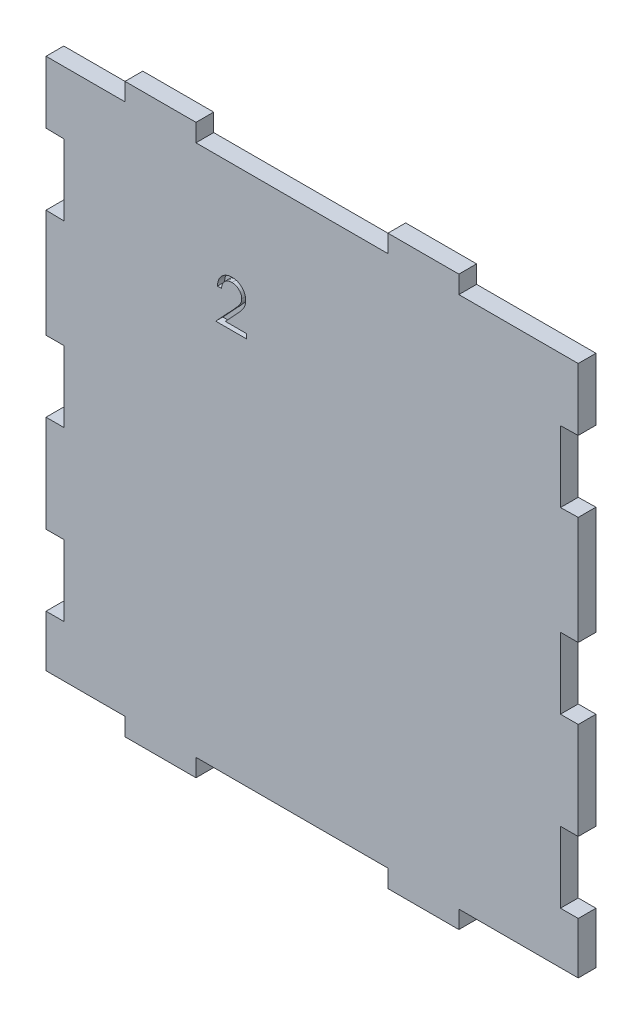
from build123d import *

# Parameters (mm, degrees)
BOSS_EXTRUDE1_DEPTH = 5
CUT_EXTRUDE1_DEPTH  = 2


with BuildPart() as part:
    # Sketch1 → Boss-Extrude1 (new body)
    with BuildSketch(Plane.XY):
        Polygon((-73.645107518, -74.864510752), (-51.383851785, -74.864510752), (-51.383851785, -79.864510752), (-31.383851785, -79.864510752), (-31.383851785, -74.864510752), (22.715789763, -74.864510752), (22.715789763, -79.864510752), (42.715789763, -79.864510752), (42.715789763, -74.864510752), (76.354892482, -74.864510752), (76.354892482, -60.328664174), (71.354892482, -60.328664174), (71.354892482, -40.328664174), (76.354892482, -40.328664174), (76.354892482, -12.973595237), (71.354892482, -12.973595237), (71.354892482, 7.026404763), (76.354892482, 7.026404763), (76.354892482, 37.571193369), (71.355899646, 37.470840861), (71.355899646, 57.470840861), (76.354892482, 57.571193369), (76.354892482, 75.135489248), (42.715789763, 75.135489248), (42.715789763, 80.135489248), (22.715789763, 80.135489248), (22.715789763, 75.135489248), (-31.383851785, 75.135489248), (-31.383851785, 80.135489248), (-51.383851785, 80.135489248), (-51.383851785, 75.135489248), (-73.645107518, 75.135489248), (-73.645107518, 57.571193369), (-68.646114682, 57.470840861), (-68.646114682, 37.470840861), (-73.645107518, 37.571193369), (-73.645107518, 7.026404763), (-68.645107518, 7.026404763), (-68.645107518, -12.973595237), (-73.645107518, -12.973595237), (-73.645107518, -40.328664174), (-68.645107518, -40.328664174), (-68.645107518, -60.328664174), (-73.645107518, -60.328664174), align=None)
    extrude(amount=BOSS_EXTRUDE1_DEPTH)

    # Sketch2 → Cut-Extrude1 (cut)
    with BuildSketch(Plane.XY.offset(5)):
        with BuildLine():
            Line((-24.19666878, 43.178385546), (-25.33641237, 43.178385546))
            add(Edge.make_bspline(
                [(-25.33641237, 43.178385546), (-25.328984129, 43.329591339), (-25.314395262, 43.626555492), (-25.246075469, 44.059530809), (-25.148318572, 44.473386793), (-25.01010101, 44.864800481), (-24.838446802, 45.237232725), (-24.632597846, 45.58920421), (-24.38878016, 45.919372238), (-24.112258582, 46.22467604), (-23.811926663, 46.504756655), (-23.487873683, 46.746619964), (-23.147350298, 46.950972657), (-22.791389622, 47.121810306), (-22.415975577, 47.250043461), (-22.024514921, 47.345190554), (-21.615287769, 47.402436151), (-21.33646826, 47.40858943), (-21.194665575, 47.41171888)],
                knots=[0, 0, 0, 0, 0.000453872, 0.000891393, 0.001312835, 0.001728009, 0.002134376, 0.002541468, 0.002949043, 0.00336336, 0.003775633, 0.004179123, 0.004573978, 0.004965443, 0.005361289, 0.005761752, 0.006172633, 0.006597866, 0.006597866, 0.006597866, 0.006597866], degree=3))
            add(Edge.make_bspline(
                [(-21.194665575, 47.41171888), (-21.055407992, 47.408458766), (-20.781771816, 47.40205276), (-20.382403935, 47.347039882), (-20.002212038, 47.260877307), (-19.641939285, 47.139989939), (-19.304460136, 46.977486445), (-18.987239375, 46.782278234), (-18.686500433, 46.556509131), (-18.415784389, 46.290702437), (-18.16719793, 46.006939499), (-17.952741176, 45.703997677), (-17.769087697, 45.391108555), (-17.616006687, 45.065886223), (-17.503317269, 44.725268492), (-17.417762057, 44.374214356), (-17.369402584, 44.009090042), (-17.361980619, 43.76196054), (-17.358207242, 43.636318239)],
                knots=[0, 0, 0, 0, 0.000417607, 0.000820584, 0.001206914, 0.001585844, 0.001957948, 0.002327951, 0.002701938, 0.003083379, 0.003463911, 0.003832406, 0.004194997, 0.004551257, 0.004908462, 0.005269442, 0.005633919, 0.006010863, 0.006010863, 0.006010863, 0.006010863], degree=3))
            add(Edge.make_bspline(
                [(-17.358207242, 43.636318239), (-17.364327354, 43.459426074), (-17.376460178, 43.108745951), (-17.481165156, 42.592747282), (-17.642934479, 42.092348925), (-17.839142328, 41.689653506), (-18.037336959, 41.366794494), (-18.212160789, 41.09858631), (-18.421356469, 40.812559028), (-18.66300994, 40.505831861), (-18.933475694, 40.177466576), (-19.234700346, 39.827328424), (-19.568984994, 39.459136174), (-19.803601825, 39.207655081), (-19.925174389, 39.07734388)],
                knots=[0, 0, 0, 0, 0.000530199, 0.001051094, 0.001573224, 0.002104594, 0.002389938, 0.002709581, 0.003064778, 0.003452579, 0.003880929, 0.004340927, 0.00483807, 0.005372718, 0.005372718, 0.005372718, 0.005372718], degree=3))
            Line((-19.925174389, 39.07734388), (-23.10271846, 35.688641956))
            Line((-23.10271846, 35.688641956), (-17.195386729, 35.688641956))
            Line((-17.195386729, 35.688641956), (-17.195386729, 34.386077854))
            Line((-17.195386729, 34.386077854), (-25.824873909, 34.386077854))
            Line((-25.824873909, 34.386077854), (-20.899553396, 39.642127533))
            add(Edge.make_bspline(
                [(-20.899553396, 39.642127533), (-20.779636778, 39.767307103), (-20.549301497, 40.007751437), (-20.223519004, 40.358790178), (-19.930914675, 40.684452798), (-19.669594421, 40.984123988), (-19.44522713, 41.262187105), (-19.246119317, 41.509636458), (-19.08658703, 41.737345463), (-18.913448308, 42.001289977), (-18.745757576, 42.323551813), (-18.601658455, 42.717374057), (-18.513793148, 43.122784374), (-18.503252745, 43.396748909), (-18.497950832, 43.534555418)],
                knots=[0, 0, 0, 0, 0.000520043, 0.000998896, 0.001436661, 0.001833471, 0.002191472, 0.002508543, 0.002785952, 0.003025175, 0.003455296, 0.003872183, 0.004280329, 0.004693418, 0.004693418, 0.004693418, 0.004693418], degree=3))
            add(Edge.make_bspline(
                [(-18.497950832, 43.534555418), (-18.500257668, 43.621210778), (-18.504803999, 43.791991852), (-18.544927645, 44.042384178), (-18.60556291, 44.283919359), (-18.692449989, 44.517340349), (-18.807137303, 44.740300286), (-18.94674071, 44.953070571), (-19.107813226, 45.158770531), (-19.294144974, 45.35164107), (-19.498838203, 45.528284301), (-19.715080195, 45.684763125), (-19.943862002, 45.815533613), (-20.184219016, 45.922734303), (-20.435481148, 46.006827829), (-20.698134366, 46.065097531), (-20.97145294, 46.101682544), (-21.158083053, 46.10663254), (-21.253179197, 46.109154777)],
                knots=[0, 0, 0, 0, 0.000259807, 0.000512029, 0.000758843, 0.001005985, 0.001257437, 0.001509351, 0.001768409, 0.002040101, 0.00231246, 0.002578628, 0.002839591, 0.003101519, 0.003367006, 0.003633016, 0.003907552, 0.004192772, 0.004192772, 0.004192772, 0.004192772], degree=3))
            add(Edge.make_bspline(
                [(-21.253179197, 46.109154777), (-21.352496219, 46.106560231), (-21.547538451, 46.101464972), (-21.833901799, 46.065822734), (-22.10708162, 46.004333542), (-22.367765097, 45.920235323), (-22.616393308, 45.813342875), (-22.851757125, 45.680204258), (-23.07332818, 45.521332726), (-23.281522993, 45.341208422), (-23.473343717, 45.140665983), (-23.641879524, 44.917109831), (-23.789141518, 44.674621781), (-23.917626451, 44.413856126), (-24.021968527, 44.132446696), (-24.101699673, 43.831392453), (-24.164789088, 43.512000583), (-24.18586572, 43.291437561), (-24.19666878, 43.178385546)],
                knots=[0, 0, 0, 0, 0.000297928, 0.000585081, 0.00086406, 0.001136798, 0.001405713, 0.001674567, 0.001946354, 0.002222301, 0.00249943, 0.002777246, 0.003060416, 0.003349412, 0.003648067, 0.00395911, 0.004282927, 0.004623434, 0.004623434, 0.004623434, 0.004623434], degree=3))
        make_face()
    extrude(amount=-CUT_EXTRUDE1_DEPTH, mode=Mode.SUBTRACT)


solid = part.part
